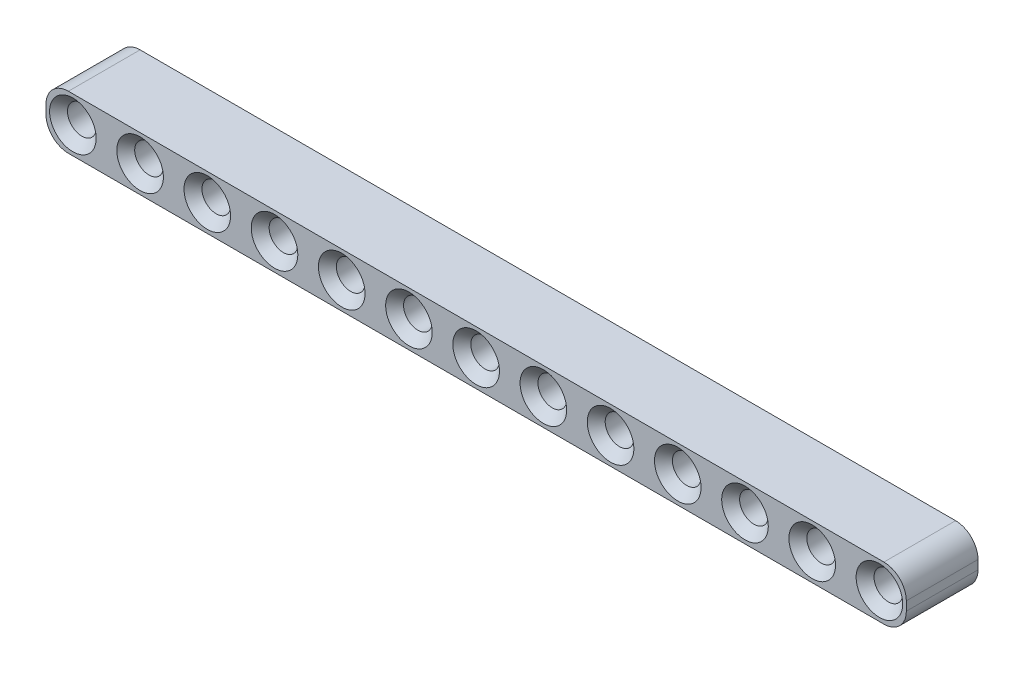
from build123d import *

# Parameters (mm, degrees)
SKETCH1_R           = 1.6
BOSS_EXTRUDE1_DEPTH = 8
CHAMFER1_SIZE       = 1


with BuildPart() as part:
    # Sketch1 → Boss-Extrude1 (new body)
    with BuildSketch(Plane.XY):
        with BuildLine():
            Line((-0.5, 3), (90.5, 3))
            ThreePointArc((90.5, 3), (92.267766953, 2.267766953), (93, 0.5))
            Line((93, 0.5), (93, -0.5))
            ThreePointArc((93, -0.5), (92.267766953, -2.267766953), (90.5, -3))
            Line((90.5, -3), (-0.5, -3))
            ThreePointArc((-0.5, -3), (-2.267766953, -2.267766953), (-3, -0.5))
            Line((-3, -0.5), (-3, 0.5))
            ThreePointArc((-3, 0.5), (-2.267766953, 2.267766953), (-0.5, 3))
        make_face()
        Circle(SKETCH1_R, mode=Mode.SUBTRACT)
        with Locations((7.5, 0)):
            Circle(SKETCH1_R, mode=Mode.SUBTRACT)
        with Locations((15, 0)):
            Circle(SKETCH1_R, mode=Mode.SUBTRACT)
        with Locations((22.5, 0)):
            Circle(SKETCH1_R, mode=Mode.SUBTRACT)
        with Locations((30, 0)):
            Circle(SKETCH1_R, mode=Mode.SUBTRACT)
        with Locations((37.5, 0)):
            Circle(SKETCH1_R, mode=Mode.SUBTRACT)
        with Locations((45, 0)):
            Circle(SKETCH1_R, mode=Mode.SUBTRACT)
        with Locations((52.5, 0)):
            Circle(SKETCH1_R, mode=Mode.SUBTRACT)
        with Locations((60, 0)):
            Circle(SKETCH1_R, mode=Mode.SUBTRACT)
        with Locations((67.5, 0)):
            Circle(SKETCH1_R, mode=Mode.SUBTRACT)
        with Locations((75, 0)):
            Circle(SKETCH1_R, mode=Mode.SUBTRACT)
        with Locations((82.5, 0)):
            Circle(SKETCH1_R, mode=Mode.SUBTRACT)
        with Locations((90, 0)):
            Circle(SKETCH1_R, mode=Mode.SUBTRACT)
    extrude(amount=BOSS_EXTRUDE1_DEPTH)

    # Chamfer1
    chamfer1_edges = [part.edges().sort_by_distance(p)[0] for p in [
        (-1.6, 0, 0),
        (-1.6, 0, 8),
        (5.9, 0, 0),
        (5.9, 0, 8),
        (13.4, 0, 0),
        (13.4, 0, 8),
        (20.9, 0, 0),
        (20.9, 0, 8),
        (28.4, 0, 0),
        (28.4, 0, 8),
        (35.9, 0, 0),
        (35.9, 0, 8),
        (43.4, 0, 0),
        (43.4, 0, 8),
        (50.9, 0, 0),
        (50.9, 0, 8),
        (58.4, 0, 0),
        (58.4, 0, 8),
        (65.9, 0, 0),
        (65.9, 0, 8),
        (73.4, 0, 0),
        (73.4, 0, 8),
        (80.9, 0, 0),
        (80.9, 0, 8),
        (88.4, 0, 0),
        (88.4, 0, 8),
    ]]
    chamfer(chamfer1_edges, length=CHAMFER1_SIZE)


solid = part.part
